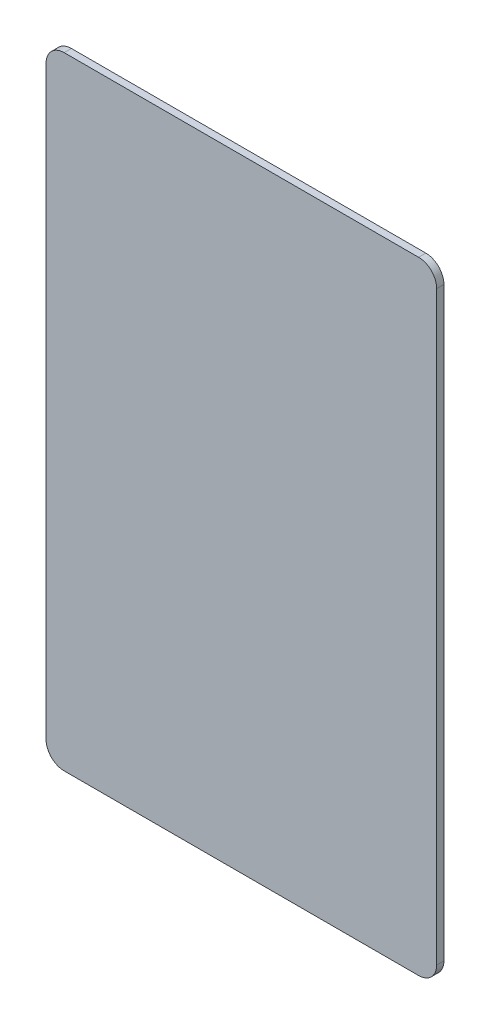
from build123d import *

# Parameters (mm, degrees)
DODANIE_WYCI_GNI_CIE1_DEPTH = 1


with BuildPart() as part:
    # Szkic1 → Dodanie-wyciągnięcie1 (new body)
    with BuildSketch(Plane.XY):
        with BuildLine():
            Line((-24.5, 43), (24.5, 43))
            ThreePointArc((24.5, 43), (26.267766953, 42.267766953), (27, 40.5))
            Line((27, 40.5), (27, -40.5))
            ThreePointArc((27, -40.5), (26.267766953, -42.267766953), (24.5, -43))
            Line((24.5, -43), (-24.5, -43))
            ThreePointArc((-24.5, -43), (-26.267766953, -42.267766953), (-27, -40.5))
            Line((-27, -40.5), (-27, 40.5))
            ThreePointArc((-27, 40.5), (-26.267766953, 42.267766953), (-24.5, 43))
        make_face()
    extrude(amount=DODANIE_WYCI_GNI_CIE1_DEPTH)


solid = part.part
